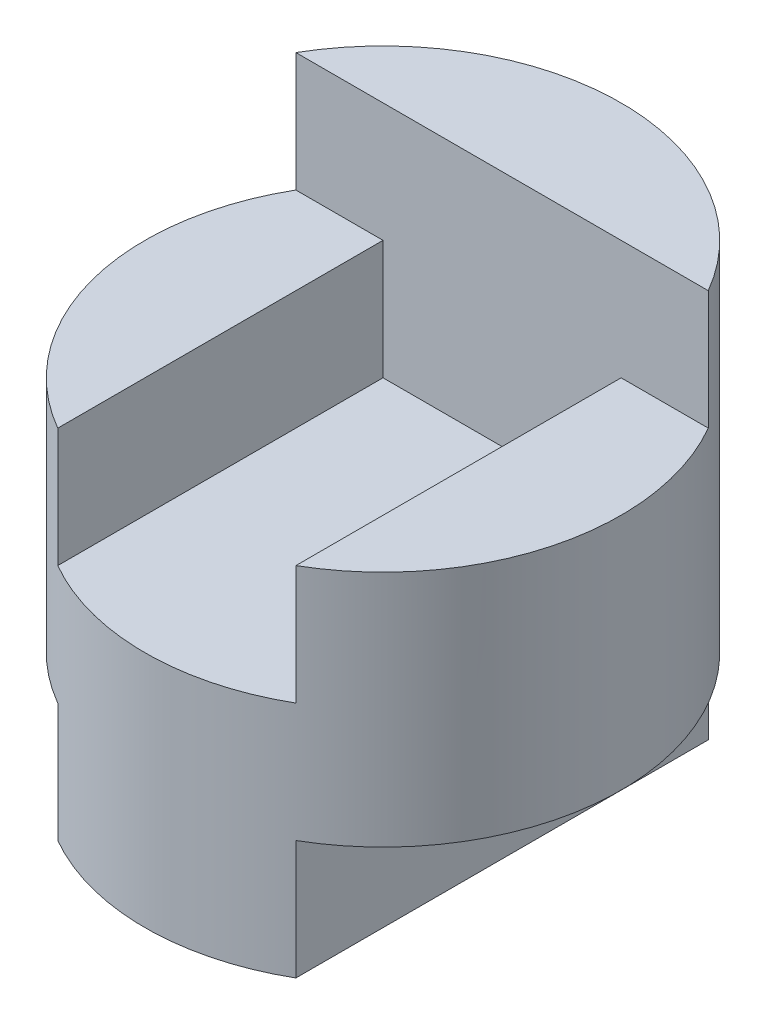
from build123d import *

# Parameters (mm, degrees)
SKETCH1_R               = 2
BOSS_EXTRUDE1_DEPTH     = 4
SKETCH2_W               = 1
SKETCH2_H               = 1
CUT_EXTRUDE1_DEPTH      = 2
CUT_EXTRUDE2_DEPTH      = 4
CUT_EXTRUDE2_DEPTH_BACK = 1


with BuildPart() as part:
    # Sketch1 → Boss-Extrude1 (new body)
    with BuildSketch(Plane(origin=(0, 0, 0), x_dir=(1, 0, 0), z_dir=(0, 1, 0))):
        Circle(SKETCH1_R)
    extrude(amount=BOSS_EXTRUDE1_DEPTH)

    # Sketch2 → Cut-Extrude1 (cut, symmetric)
    with BuildSketch(Plane.XY):
        with Locations((-1.5, 0.5)):
            Rectangle(SKETCH2_W, SKETCH2_H)
        with Locations((1.5, 0.5)):
            Rectangle(SKETCH2_W, SKETCH2_H)
    extrude(amount=CUT_EXTRUDE1_DEPTH, both=True, mode=Mode.SUBTRACT)

    # Sketch3 → Cut-Extrude2 (cut, two sides)
    with BuildSketch(Plane.XY) as cut_extrude2_sk:
        Polygon((-2, 4), (2, 4), (2, 3), (1, 3), (1, 2), (-1, 2), (-1, 3), (-2, 3), align=None)
    extrude(amount=CUT_EXTRUDE2_DEPTH, mode=Mode.SUBTRACT)
    extrude(cut_extrude2_sk.sketch, amount=-CUT_EXTRUDE2_DEPTH_BACK, mode=Mode.SUBTRACT)


solid = part.part
